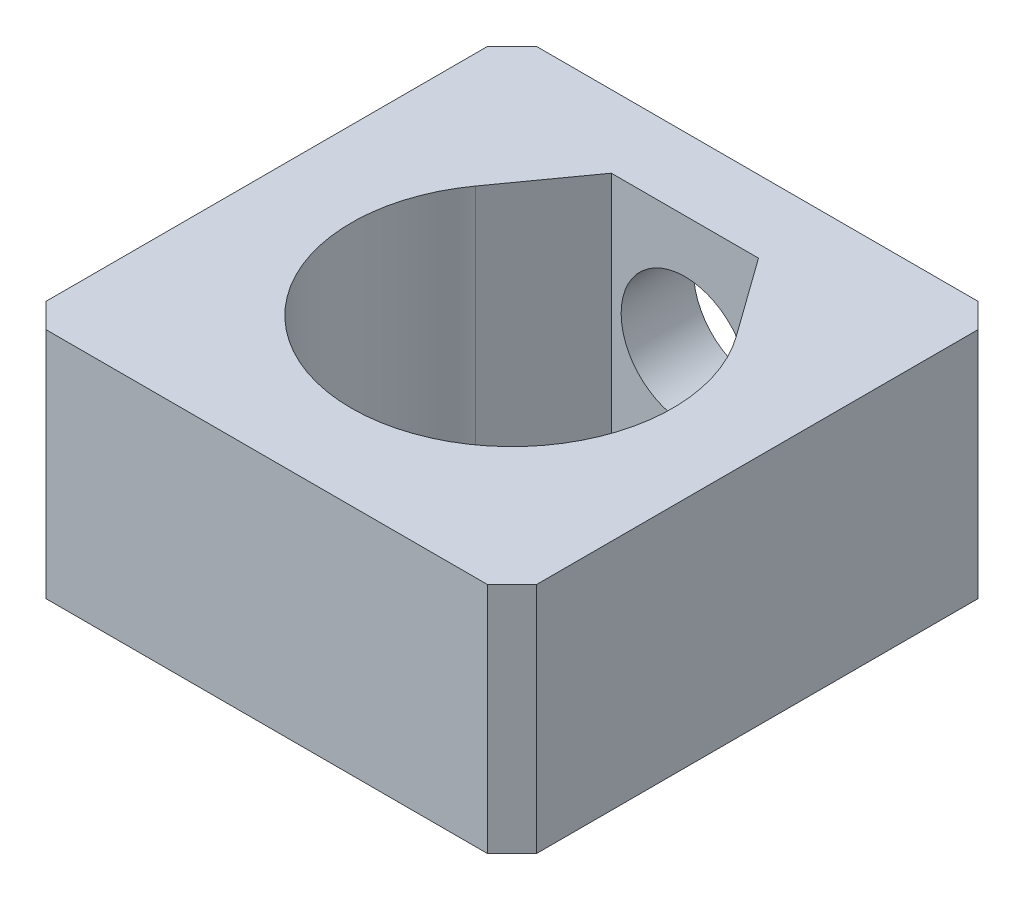
from build123d import *

# Parameters (mm, degrees)
SKETCH1_W           = 20
SKETCH1_H           = 20
BOSS_EXTRUDE1_DEPTH = 9.5
CUT_EXTRUDE1_REACH  = 22
SKETCH3_R           = 2.6
CHAMFER1_SIZE       = 1


with BuildPart() as part:
    # Sketch1 → Boss-Extrude1 (new body)
    with BuildSketch(Plane(origin=(0, 0, 0), x_dir=(1, 0, 0), z_dir=(0, 1, 0))):
        Rectangle(SKETCH1_W, SKETCH1_H)
        with BuildLine():
            Line((-5.319354919, 3.821905708), (-3, 7.05))
            Line((-3, 7.05), (3, 7.05))
            Line((3, 7.05), (5.319354919, 3.821905708))
            ThreePointArc((5.319354919, 3.821905708), (0, -6.55), (-5.319354919, 3.821905708))
        make_face(mode=Mode.SUBTRACT)
    extrude(amount=BOSS_EXTRUDE1_DEPTH)

    # Sketch3 → Cut-Extrude1 (cut, up to next)
    with BuildSketch(Plane(origin=(0, 0, -10), x_dir=(-1, 0, 0), z_dir=(0, 0, -1)), mode=Mode.PRIVATE) as cut_extrude1_sk1:
        with Locations((0, 4.75)):
            Circle(SKETCH3_R)
    cut_extrude1_tool1 = extrude(cut_extrude1_sk1.sketch, amount=-CUT_EXTRUDE1_REACH, mode=Mode.PRIVATE) & part.part
    add(cut_extrude1_tool1.solids().sort_by_distance((0, 4.75, -10))[0], mode=Mode.SUBTRACT)

    # Chamfer1
    chamfer1_edges = [part.edges().sort_by_distance(p)[0] for p in [
        (-10, 4.75, -10),
        (10, 4.75, -10),
        (10, 4.75, 10),
        (-10, 4.75, 10),
    ]]
    chamfer(chamfer1_edges, length=CHAMFER1_SIZE)


solid = part.part
